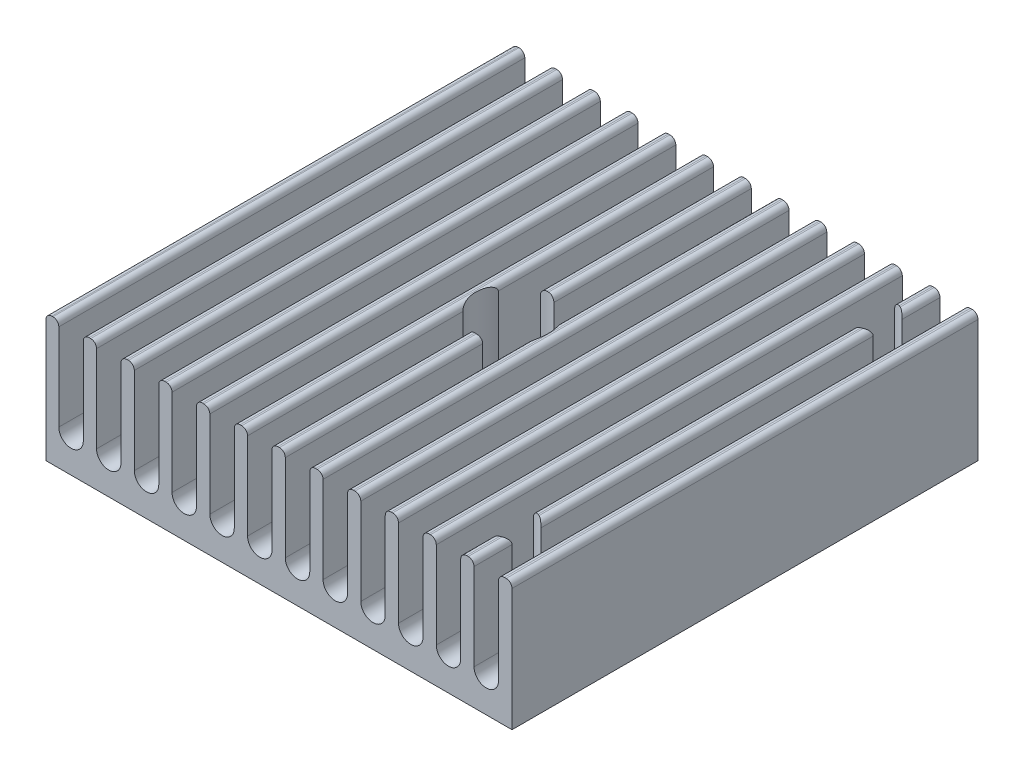
from build123d import *

# Parameters (mm, degrees)
SKETCH_1_W             = 40
SKETCH_1_H             = 11
EXTRUDE_1_DEPTH        = 40
CUT_EXTRUDE_1_DEPTH    = 40
PATTERN_LINEAR_1_COUNT = 12
PATTERN_LINEAR_1_PITCH = 3.24
FILLET_1_R             = 0.5
FILLET_2_R             = 0.5
SKETCH_3_R             = 3.1
CUT_EXTRUDE_2_DEPTH    = 40
SKETCH_4_R             = 1.75
CUT_EXTRUDE_3_DEPTH    = 17


with BuildPart() as part:
    # Эскиз1 → Бобышка-Вытянуть1 (new body)
    with BuildSketch(Plane.XY):
        with Locations((20, 5.5)):
            Rectangle(SKETCH_1_W, SKETCH_1_H)
    extrude(amount=EXTRUDE_1_DEPTH)

    # Эскиз2 → Вырез-Вытянуть1 (cut)
    with BuildSketch(Plane(origin=(0, 0, 0), x_dir=(-1, 0, 0), z_dir=(0, 0, -1))):
        with BuildLine():
            Line((-3.2, 3.05), (-3.2, 15.274907047))
            ThreePointArc((-3.2, 15.274907047), (-2.15, 16.324907047), (-1.1, 15.274907047))
            Line((-1.1, 15.274907047), (-1.1, 3.05))
            ThreePointArc((-1.1, 3.05), (-2.15, 2), (-3.2, 3.05))
        make_face()
    cut_extrude_1 = extrude(amount=-CUT_EXTRUDE_1_DEPTH, mode=Mode.SUBTRACT)

    # Линейный массив1: Вырез-Вытянуть1 ×12
    with Locations(*[(i * PATTERN_LINEAR_1_PITCH, 0, 0) for i in range(1, PATTERN_LINEAR_1_COUNT)]):
        add(cut_extrude_1, mode=Mode.SUBTRACT)

    # Скругление1
    fillet_1_edges = [part.edges().sort_by_distance(p)[0] for p in [
        (1.1, 11, 20),
        (0, 11, 20),
    ]]
    fillet(fillet_1_edges, radius=FILLET_1_R)

    # Скругление2
    fillet_2_edges = [part.edges().sort_by_distance(p)[0] for p in [
        (19.4, 11, 20),
        (17.3, 11, 20),
        (22.64, 11, 20),
        (20.54, 11, 20),
        (25.88, 11, 20),
        (23.78, 11, 20),
        (29.12, 11, 20),
        (27.02, 11, 20),
        (32.36, 11, 20),
        (30.26, 11, 20),
        (3.2, 11, 20),
        (35.6, 11, 20),
        (33.5, 11, 20),
        (38.84, 11, 20),
        (36.74, 11, 20),
        (6.44, 11, 20),
        (4.34, 11, 20),
        (9.68, 11, 20),
        (7.58, 11, 20),
        (12.92, 11, 20),
        (40, 11, 20),
        (10.82, 11, 20),
        (16.16, 11, 20),
        (14.06, 11, 20),
    ]]
    fillet(fillet_2_edges, radius=FILLET_2_R)

    # Эскиз3 → Вырез-Вытянуть2 (cut)
    with BuildSketch(Plane.XZ):
        with Locations((20, 20)):
            Circle(SKETCH_3_R)
    extrude(amount=-CUT_EXTRUDE_2_DEPTH, mode=Mode.SUBTRACT)

    # Эскиз4 → Вырез-Вытянуть3 (cut)
    with BuildSketch(Plane.XZ):
        with Locations((35.5, 35.5)):
            Circle(SKETCH_4_R)
        with Locations((35.5, 4.5)):
            Circle(SKETCH_4_R)
    extrude(amount=-CUT_EXTRUDE_3_DEPTH, mode=Mode.SUBTRACT)


solid = part.part
